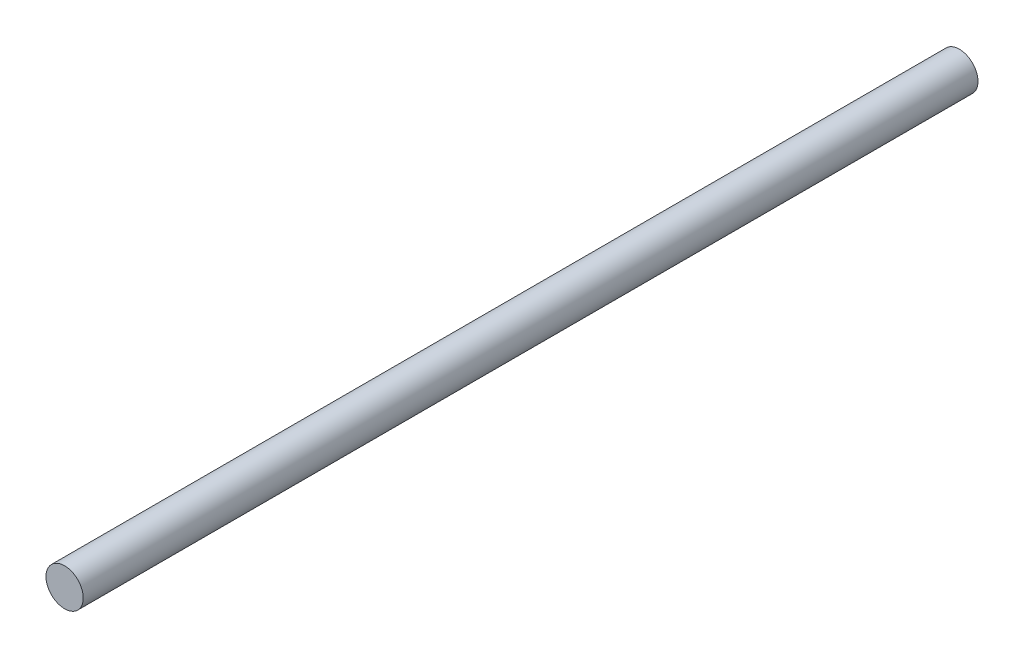
from build123d import *

# Parameters (mm, degrees)
CROQUIS2_R              = 2.5
SALIENTE_EXTRUIR1_DEPTH = 120


with BuildPart() as part:
    # Croquis2 → Saliente-Extruir1 (new body)
    with BuildSketch(Plane.XY):
        Circle(CROQUIS2_R)
    extrude(amount=SALIENTE_EXTRUIR1_DEPTH)


solid = part.part
